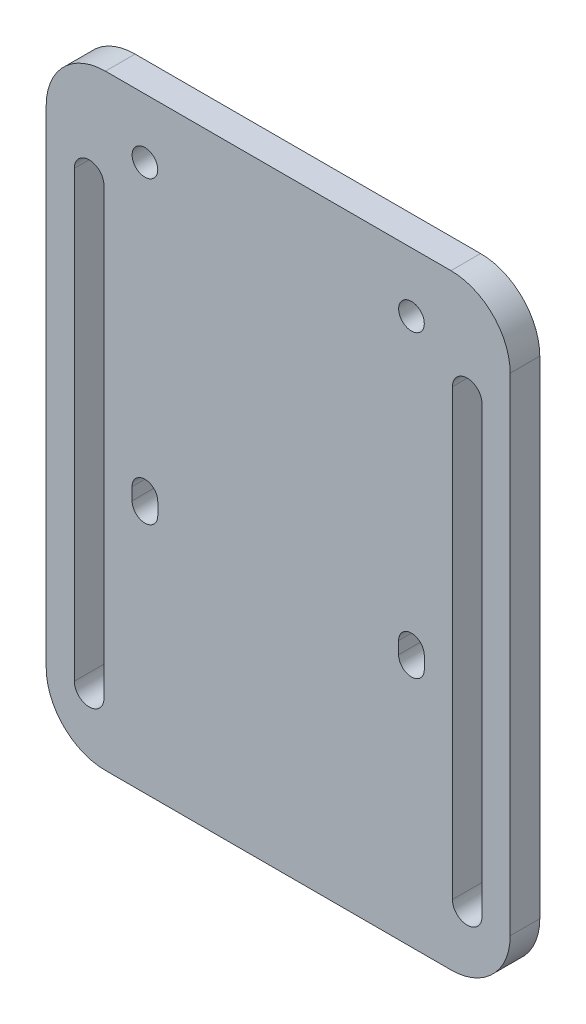
from build123d import *

# Parameters (mm, degrees)
MODEL_R    = 2.6
BASE_DEPTH = 6


with BuildPart() as part:
    # Model → Base (new body)
    with BuildSketch(Plane.XY):
        with BuildLine():
            Line((35, 0), (-35, 0))
            ThreePointArc((-35, 0), (-43.485281374, 3.514718626), (-47, 12))
            Line((-47, 12), (-47, 110.7))
            ThreePointArc((-47, 110.7), (-43.485281374, 119.185281374), (-35, 122.7))
            Line((-35, 122.7), (35, 122.7))
            ThreePointArc((35, 122.7), (43.485281374, 119.185281374), (47, 110.7))
            Line((47, 110.7), (47, 12))
            ThreePointArc((47, 12), (43.485281374, 3.514718626), (35, 0))
        make_face()
        with Locations((27, 110.7)):
            Circle(MODEL_R, mode=Mode.SUBTRACT)
        with Locations((-27, 110.7)):
            Circle(MODEL_R, mode=Mode.SUBTRACT)
        with BuildLine():
            Line((-29.6, 52.5), (-29.6, 50))
            ThreePointArc((-29.6, 50), (-27, 47.4), (-24.4, 50))
            Line((-24.4, 50), (-24.4, 52.5))
            ThreePointArc((-24.4, 52.5), (-27, 55.1), (-29.6, 52.5))
        make_face(mode=Mode.SUBTRACT)
        with BuildLine():
            Line((-41.3, 102.5), (-41.3, 12.5))
            ThreePointArc((-41.3, 12.5), (-38.3, 9.5), (-35.3, 12.5))
            Line((-35.3, 12.5), (-35.3, 102.5))
            ThreePointArc((-35.3, 102.5), (-38.3, 105.5), (-41.3, 102.5))
        make_face(mode=Mode.SUBTRACT)
        with BuildLine():
            Line((24.4, 52.5), (24.4, 50))
            ThreePointArc((24.4, 50), (27, 47.4), (29.6, 50))
            Line((29.6, 50), (29.6, 52.5))
            ThreePointArc((29.6, 52.5), (27, 55.1), (24.4, 52.5))
        make_face(mode=Mode.SUBTRACT)
        with BuildLine():
            Line((41.3, 12.5), (41.3, 102.5))
            ThreePointArc((41.3, 102.5), (38.3, 105.5), (35.3, 102.5))
            Line((35.3, 102.5), (35.3, 12.5))
            ThreePointArc((35.3, 12.5), (38.3, 9.5), (41.3, 12.5))
        make_face(mode=Mode.SUBTRACT)
    extrude(amount=BASE_DEPTH)


solid = part.part
